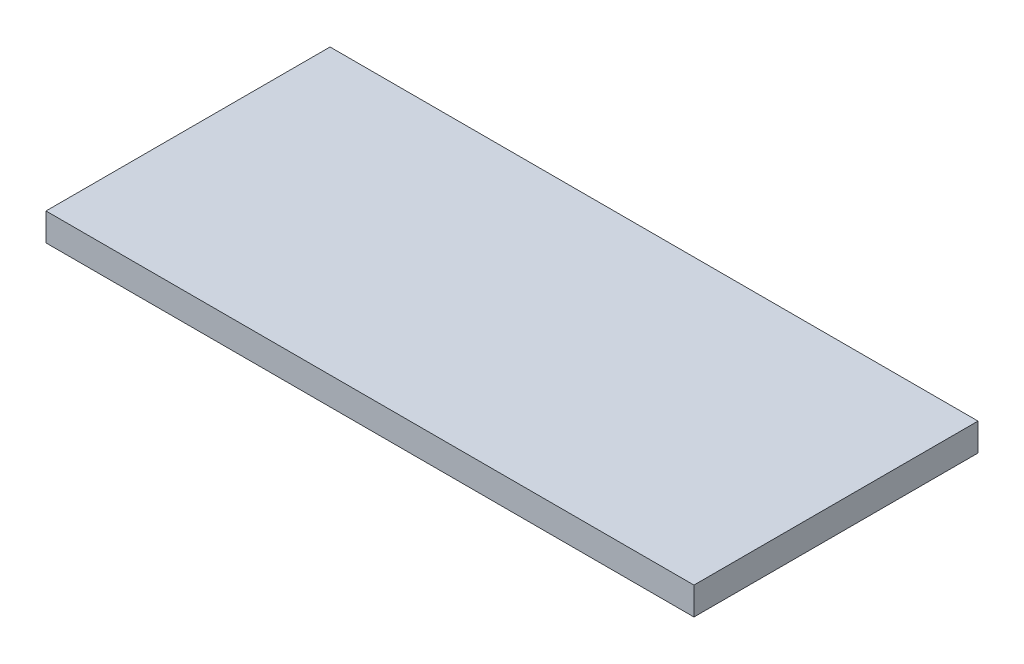
from build123d import *

# Parameters (mm, degrees)
SKETCH1_W           = 36.5
SKETCH1_H           = 16
BOSS_EXTRUDE1_DEPTH = 1.56


with BuildPart() as part:
    # Sketch1 → Boss-Extrude1 (new body)
    with BuildSketch(Plane(origin=(0, 0, 0), x_dir=(1, 0, 0), z_dir=(0, 1, 0))):
        with Locations((18.25, 8)):
            Rectangle(SKETCH1_W, SKETCH1_H)
    extrude(amount=BOSS_EXTRUDE1_DEPTH)


solid = part.part
